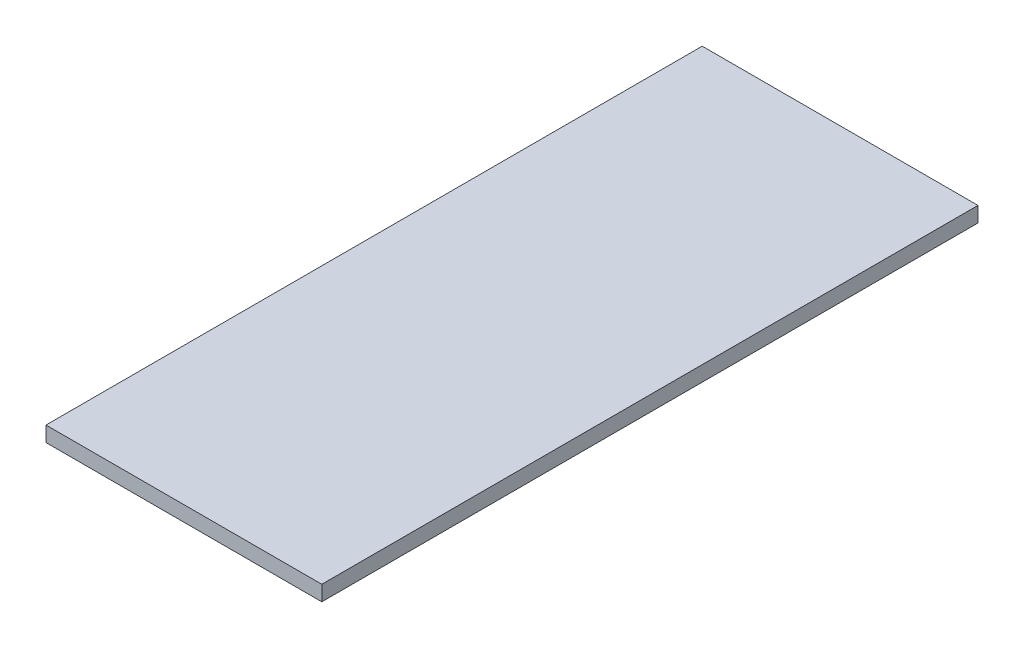
from build123d import *

# Parameters (mm, degrees)
SKETCH1_W      = 290
SKETCH1_H      = 690
EXTRUDE1_DEPTH = 16


with BuildPart() as part:
    # Sketch1 → Extrude1 (new body)
    with BuildSketch(Plane(origin=(0, 0, 0), x_dir=(1, 0, 0), z_dir=(0, 1, 0))):
        with Locations((145, 345)):
            Rectangle(SKETCH1_W, SKETCH1_H)
    extrude(amount=EXTRUDE1_DEPTH)


solid = part.part
